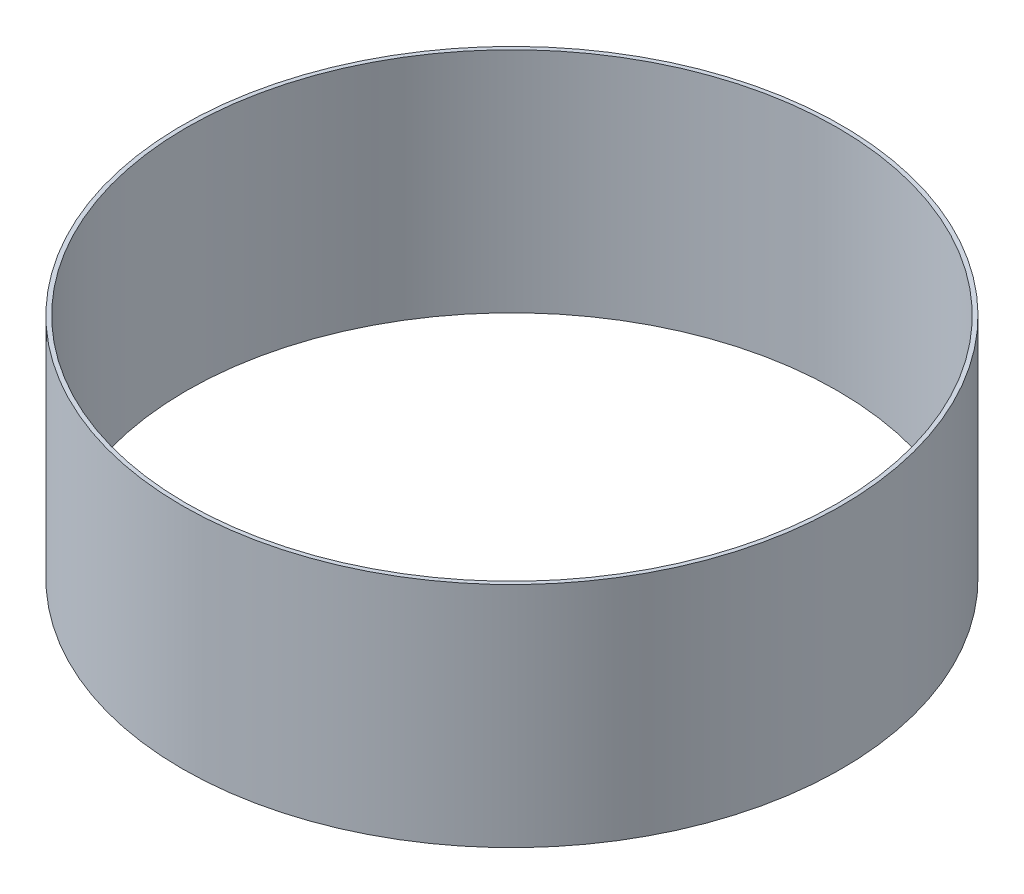
from build123d import *

# Parameters (mm, degrees)
SKETCH1_R           = 128.5875
SKETCH1_R_2         = 127
BOSS_EXTRUDE1_DEPTH = 88.9


with BuildPart() as part:
    # Sketch1 → Boss-Extrude1 (new body)
    with BuildSketch(Plane(origin=(0, 0, 0), x_dir=(1, 0, 0), z_dir=(0, 1, 0))):
        with Locations(Location((0, 0, 0), (0, 0, 270))):  # turned: the seam where the file's is
            Circle(SKETCH1_R)
        with Locations(Location((0, 0, 0), (0, 0, 270))):  # turned: the seam where the file's is
            Circle(SKETCH1_R_2, mode=Mode.SUBTRACT)
    extrude(amount=BOSS_EXTRUDE1_DEPTH)


solid = part.part
